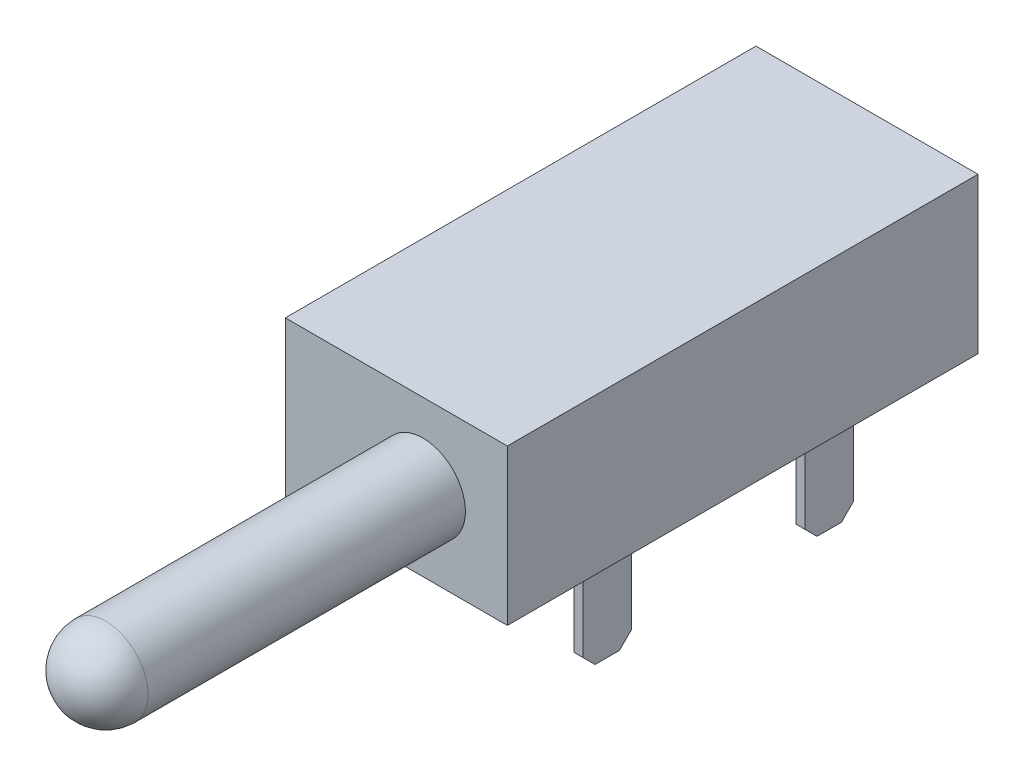
from build123d import *

# Parameters (mm, degrees)
SKETCH1_W           = 12.7
SKETCH1_H           = 8.89
BOSS_EXTRUDE1_DEPTH = 26.924
SKETCH2_R           = 2.4257
BOSS_EXTRUDE2_DEPTH = 20.574
FILLET1_R           = 2.4257
SKETCH3_W           = 0.508
SKETCH3_H           = 2.794
BOSS_EXTRUDE3_DEPTH = 7.112
CHAMFER1_SIZE       = 0.6985


with BuildPart() as part:
    # Sketch1 → Boss-Extrude1 (new body)
    with BuildSketch(Plane.XY):
        with Locations((-1.524, 0)):
            Rectangle(SKETCH1_W, SKETCH1_H)
    extrude(amount=-BOSS_EXTRUDE1_DEPTH)

    # Sketch2 → Boss-Extrude2 (add)
    with BuildSketch(Plane.XY):
        Circle(SKETCH2_R)
    extrude(amount=BOSS_EXTRUDE2_DEPTH)

    # Fillet1
    fillet1_edges = [part.edges().sort_by_distance(p)[0] for p in [
        (-2.4257, 0, 20.574),
    ]]
    fillet(fillet1_edges, radius=FILLET1_R)

    # Sketch3 → Boss-Extrude3 (add)
    with BuildSketch(Plane.XZ.offset(4.445)):
        with Locations((-4.953, -13.462)):
            Rectangle(SKETCH3_W, SKETCH3_H)
        with Locations((1.905, -21.082)):
            Rectangle(SKETCH3_W, SKETCH3_H)
        with Locations((1.905, -8.382)):
            Rectangle(SKETCH3_W, SKETCH3_H)
    extrude(amount=BOSS_EXTRUDE3_DEPTH)

    # Chamfer1
    chamfer1_edges = [part.edges().sort_by_distance(p)[0] for p in [
        (-4.953, -11.557, -14.859),
        (-4.953, -11.557, -12.065),
        (1.905, -11.557, -19.685),
        (1.905, -11.557, -22.479),
        (1.905, -11.557, -9.779),
        (1.905, -11.557, -6.985),
    ]]
    chamfer(chamfer1_edges, length=CHAMFER1_SIZE)


solid = part.part
